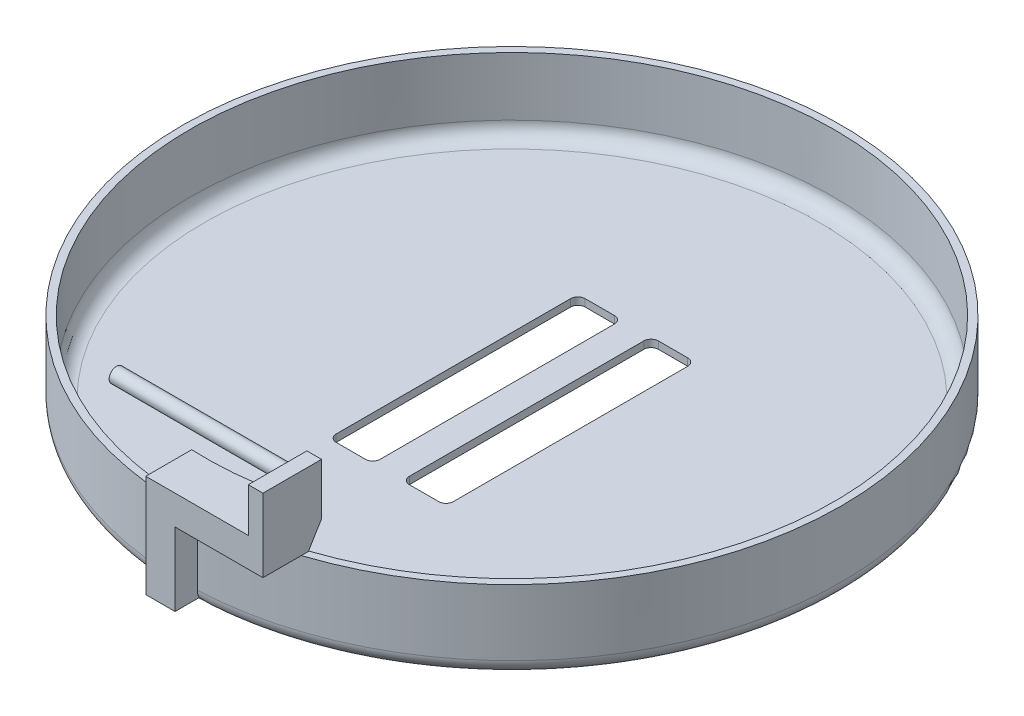
from build123d import *

# Parameters (mm, degrees)
SKETCH1_R                = 22.5
SKETCH1_R_2              = 22
BOSS_EXTRUDE1_DEPTH      = 5
BOSS_EXTRUDE2_START      = -0.5
SKETCH3_R                = 22.5
BOSS_EXTRUDE2_DEPTH      = 0.5
CUT_EXTRUDE1_DEPTH       = 10
CUT_EXTRUDE1_DEPTH_BACK  = 10
SKETCH6_W                = 3
SKETCH6_H                = 17
FILLET1_R                = 0.5
FILLET3_R                = 1
BOSS_EXTRUDE3_DEPTH      = 2
BOSS_EXTRUDE3_DEPTH_BACK = 5
SKETCH7_W                = 2
SKETCH7_H                = 4
SKETCH8_W                = 4
SKETCH8_H                = 2
BOSS_EXTRUDE4_DEPTH      = 6
SKETCH9_W                = 1
SKETCH9_H                = 4
BOSS_EXTRUDE5_DEPTH      = 3
SKETCH10_R               = 0.5
BOSS_EXTRUDE6_DEPTH      = 12


with BuildPart() as part:
    # Sketch1 → Boss-Extrude1 (new body)
    with BuildSketch(Plane(origin=(0, 0, 0), x_dir=(1, 0, 0), z_dir=(0, 1, 0))):
        Circle(SKETCH1_R)
        Circle(SKETCH1_R_2, mode=Mode.SUBTRACT)
    extrude(amount=BOSS_EXTRUDE1_DEPTH)

    # Sketch3 → Boss-Extrude2 (add)
    with BuildSketch(Plane(origin=(0, 0, 0), x_dir=(1, 0, 0), z_dir=(0, 1, 0)).offset(BOSS_EXTRUDE2_START)):
        Circle(SKETCH3_R)
    extrude(amount=BOSS_EXTRUDE2_DEPTH)

    # Sketch6 → Cut-Extrude1 (cut, two sides: drawn at the far end of the back side and taken through both)
    with BuildSketch(Plane.XZ.offset(0.5).offset(-CUT_EXTRUDE1_DEPTH_BACK)):
        with Locations((2.5, 0)):
            Rectangle(SKETCH6_W, SKETCH6_H)
        with Locations((-2.5, 0)):
            Rectangle(SKETCH6_W, SKETCH6_H)
    extrude(amount=CUT_EXTRUDE1_DEPTH + CUT_EXTRUDE1_DEPTH_BACK, mode=Mode.SUBTRACT)

    # Fillet1
    fillet1_edges = [part.edges().sort_by_distance(p)[0] for p in [
        (1, -0.25, 8.5),
        (-4, -0.25, 8.5),
        (-1, -0.25, 8.5),
        (4, -0.25, 8.5),
        (-1, -0.25, -8.5),
        (-4, -0.25, -8.5),
        (1, -0.25, -8.5),
        (4, -0.25, -8.5),
    ]]
    fillet(fillet1_edges, radius=FILLET1_R)

    # Fillet3
    fillet3_edges = [part.edges().sort_by_distance(p)[0] for p in [
        (-22.5, -0.5, 0),
        (-22, 0, 0),
    ]]
    fillet(fillet3_edges, radius=FILLET3_R)

    # Sketch7 → Boss-Extrude3 (add, two sides: drawn at the far end of the back side and taken through both)
    with BuildSketch(Plane(origin=(0, 5, 0), x_dir=(1, 0, 0), z_dir=(0, 1, 0)).offset(-BOSS_EXTRUDE3_DEPTH_BACK)):
        with Locations((0, -22)):
            Rectangle(SKETCH7_W, SKETCH7_H)
    extrude(amount=BOSS_EXTRUDE3_DEPTH + BOSS_EXTRUDE3_DEPTH_BACK)

    # Sketch8 → Boss-Extrude4 (add)
    with BuildSketch(Plane(origin=(1, 0, 0), x_dir=(0, 0, -1), z_dir=(1, 0, 0))):
        with Locations((-22, 6)):
            Rectangle(SKETCH8_W, SKETCH8_H)
    extrude(amount=BOSS_EXTRUDE4_DEPTH)

    # Sketch9 → Boss-Extrude5 (add)
    with BuildSketch(Plane(origin=(0, 7, 0), x_dir=(1, 0, 0), z_dir=(0, 1, 0))):
        with Locations((6.5, -22)):
            Rectangle(SKETCH9_W, SKETCH9_H)
    extrude(amount=BOSS_EXTRUDE5_DEPTH)

    # Sketch10 → Boss-Extrude6 (add)
    with BuildSketch(Plane.ZY.offset(-6)):
        with Locations((21, 9)):
            Circle(SKETCH10_R)
    extrude(amount=BOSS_EXTRUDE6_DEPTH)

    # Sketch12 → Cut-Revolve1 (revolve, cut)
    with BuildSketch(Plane(origin=(0, 0, 0), x_dir=(0, 0, -1), z_dir=(1, 0, 0))):
        with BuildLine():
            Line((-18, 12), (-22, 5.07179677))
            Line((-22, 5.07179677), (-22, 1))
            ThreePointArc((-22, 1), (-21.707106781, 0.292893219), (-21, 0))
            Line((-21, 0), (0, 0))
            Line((0, 0), (0, 12))
            Line((0, 12), (-18, 12))
        make_face()
    revolve(axis=Axis((0, 12.625, 0), (0, -1, 0)), mode=Mode.SUBTRACT)


solid = part.part
